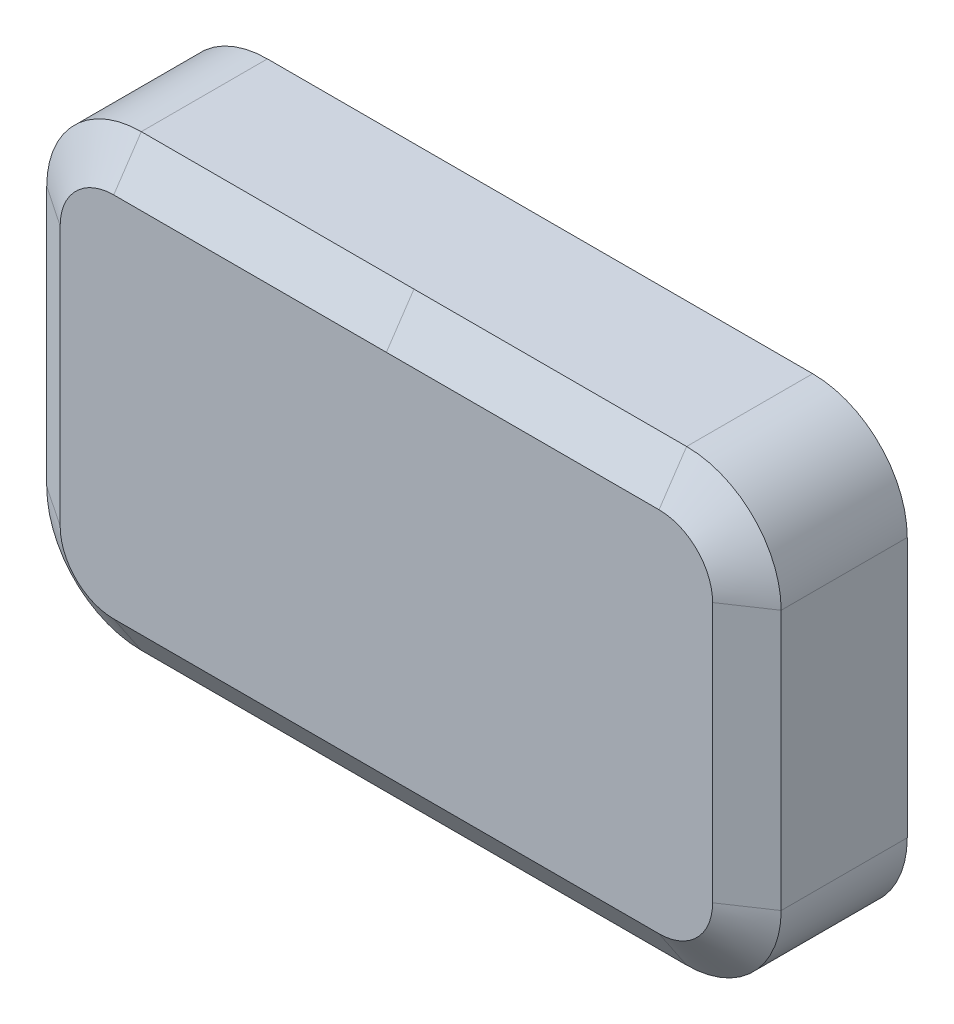
from build123d import *

# Parameters (mm, degrees)
SKETCH1_W           = 118.364
SKETCH1_H           = 72.39
BOSS_EXTRUDE1_DEPTH = 27.94
SKETCH2_R           = 4.318
BOSS_EXTRUDE2_DEPTH = 1.9558
BOSS_EXTRUDE2_TAPER = 15
FILLET1_R           = 15.24
BOSS_EXTRUDE3_DEPTH = 1.27
CUT_EXTRUDE1_DEPTH  = 4.318
SKETCH13_W          = 72.644
SKETCH13_H          = 13.208
SKETCH13_W_2        = 9.3472
SKETCH13_H_2        = 11.43
CUT_EXTRUDE2_DEPTH  = 0.635


with BuildPart() as part:
    # Sketch1 → Boss-Extrude1 (new body)
    with BuildSketch(Plane.XY):
        Rectangle(SKETCH1_W, SKETCH1_H)
    extrude(amount=BOSS_EXTRUDE1_DEPTH)

    # Sketch2 → Boss-Extrude2 (add)
    with BuildSketch(Plane(origin=(0, 0, 0), x_dir=(-1, 0, 0), z_dir=(0, 0, -1))):
        with Locations((-43.434, 21.717)):
            Circle(SKETCH2_R)
        with Locations((-43.434, -21.717)):
            Circle(SKETCH2_R)
        with Locations((43.434, -21.717)):
            Circle(SKETCH2_R)
        with Locations((43.434, 21.717)):
            Circle(SKETCH2_R)
    extrude(amount=BOSS_EXTRUDE2_DEPTH, taper=BOSS_EXTRUDE2_TAPER)

    # Fillet1
    fillet1_edges = [part.edges().sort_by_distance(p)[0] for p in [
        (-59.182, 36.195, 13.97),
        (59.182, 36.195, 13.97),
        (59.182, -36.195, 13.97),
        (-59.182, -36.195, 13.97),
    ]]
    fillet(fillet1_edges, radius=FILLET1_R)

    # Cut-Sweep1: sweep along a path in Sketch4
    with BuildLine(Plane.XY.offset(27.94)) as cut_sweep1_path:
        Line((43.942, 36.195), (-43.942, 36.195))
        ThreePointArc((-43.942, 36.195), (-54.718307345, 31.731307345), (-59.182, 20.955))
        Line((-59.182, 20.955), (-59.182, -20.955))
        ThreePointArc((-59.182, -20.955), (-54.718307345, -31.731307345), (-43.942, -36.195))
        Line((-43.942, -36.195), (43.942, -36.195))
        ThreePointArc((43.942, -36.195), (54.718307345, -31.731307345), (59.182, -20.955))
        Line((59.182, -20.955), (59.182, 20.955))
        ThreePointArc((59.182, 20.955), (54.718307345, 31.731307345), (43.942, 36.195))
    # Sketch3 → Cut-Sweep1 (sweep, cut)
    with BuildSketch(Plane(origin=(0, 0, 0), x_dir=(0, 0, -1), z_dir=(1, 0, 0))):
        Polygon((-23.495, 36.195), (-27.94, 29.591), (-27.94, 36.195), align=None)
        Polygon((0, 36.195), (0, 29.591), (-3.175, 34.417), (-3.175, 36.195), align=None)
    sweep(path=cut_sweep1_path.line, mode=Mode.SUBTRACT)

    # Sketch11 → Boss-Extrude3 (add)
    with BuildSketch(Plane(origin=(0, 0, 0), x_dir=(-1, 0, 0), z_dir=(0, 0, -1))):
        with BuildLine():
            Line((-26.67, 6.858), (-26.67, -6.858))
            ThreePointArc((-26.67, -6.858), (-32.512, -12.7), (-38.354, -6.858))
            Line((-38.354, -6.858), (-38.354, 6.858))
            ThreePointArc((-38.354, 6.858), (-32.512, 12.7), (-26.67, 6.858))
        make_face()
        with BuildLine():
            Line((26.67, 6.858), (26.67, -6.858))
            ThreePointArc((26.67, -6.858), (32.512, -12.7), (38.354, -6.858))
            Line((38.354, -6.858), (38.354, 6.858))
            ThreePointArc((38.354, 6.858), (32.512, 12.7), (26.67, 6.858))
        make_face()
    extrude(amount=BOSS_EXTRUDE3_DEPTH)

    # Sketch12 → Cut-Extrude1 (cut)
    with BuildSketch(Plane(origin=(0, 0, -1.27), x_dir=(-1, 0, 0), z_dir=(0, 0, -1))):
        with BuildLine():
            Line((-35.052, 6.858), (-35.052, 2.839806331))
            ThreePointArc((-35.052, 2.839806331), (-36.322, 0), (-35.052, -2.839806331))
            Line((-35.052, -2.839806331), (-35.052, -6.858))
            ThreePointArc((-35.052, -6.858), (-32.512, -9.398), (-29.972, -6.858))
            Line((-29.972, -6.858), (-29.972, -2.839806331))
            ThreePointArc((-29.972, -2.839806331), (-28.702, 0), (-29.972, 2.839806331))
            Line((-29.972, 2.839806331), (-29.972, 6.858))
            ThreePointArc((-29.972, 6.858), (-32.512, 9.398), (-35.052, 6.858))
        make_face()
        with BuildLine():
            Line((29.972, 2.839806331), (29.972, 6.858))
            ThreePointArc((29.972, 6.858), (32.512, 9.398), (35.052, 6.858))
            Line((35.052, 6.858), (35.052, 2.839806331))
            ThreePointArc((35.052, 2.839806331), (36.322, 0), (35.052, -2.839806331))
            Line((35.052, -2.839806331), (35.052, -6.858))
            ThreePointArc((35.052, -6.858), (32.512, -9.398), (29.972, -6.858))
            Line((29.972, -6.858), (29.972, -2.839806331))
            ThreePointArc((29.972, -2.839806331), (28.702, 0), (29.972, 2.839806331))
        make_face()
    extrude(amount=-CUT_EXTRUDE1_DEPTH, mode=Mode.SUBTRACT)

    # Sketch13 → Cut-Extrude2 (cut)
    with BuildSketch(Plane.XZ.offset(36.195)):
        with Locations((-6.4135, 14.5542)):
            Rectangle(SKETCH13_W, SKETCH13_H)
        with Locations((38.0619, 13.6652)):
            Rectangle(SKETCH13_W_2, SKETCH13_H_2)
    extrude(amount=-CUT_EXTRUDE2_DEPTH, mode=Mode.SUBTRACT)


solid = part.part
